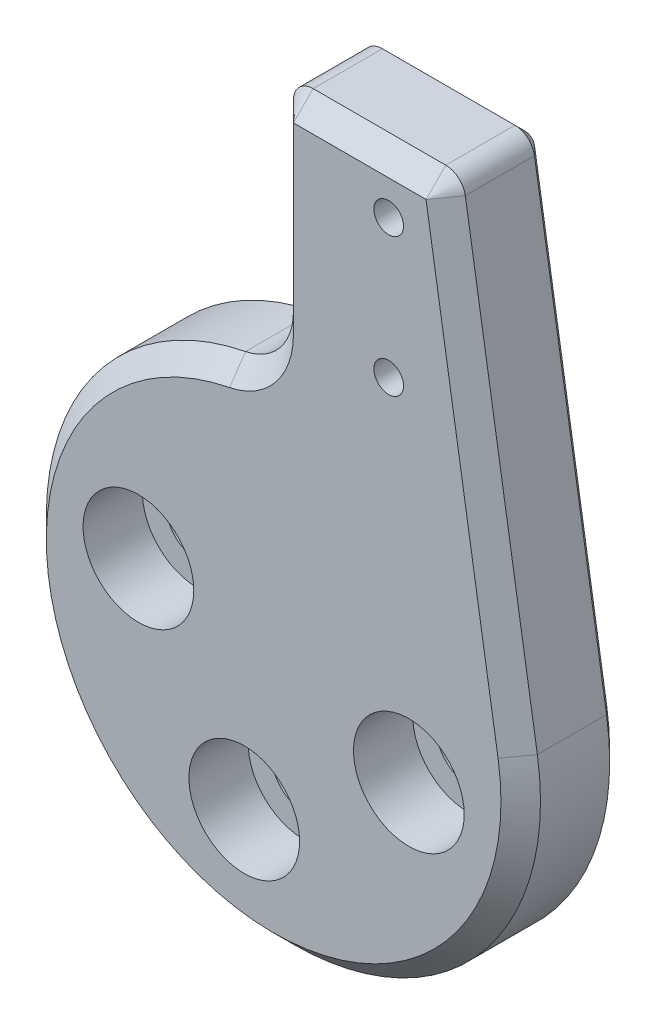
from build123d import *

# Parameters (mm, degrees)
SKETCH1_R           = 1.6
SKETCH1_R_2         = 1.6000000000000016
SKETCH1_R_3         = 0.7500000000000004
BOSS_EXTRUDE1_DEPTH = 5
CHAMFER1_SIZE       = 1
SKETCH2_R           = 2.8000000000000003
SKETCH2_R_2         = 2.8
CUT_EXTRUDE1_DEPTH  = 3
CHAMFER3_SIZE       = 0.5


with BuildPart() as part:
    # Sketch1 → Boss-Extrude1 (new body)
    with BuildSketch(Plane.XY):
        with BuildLine():
            Line((1.000000000000007, 25.491602871293395), (7.708608571885691, 25.491602871293395))
            ThreePointArc((7.708608571885691, 25.491602871293395), (8.357146361630761, 25.2527853298883), (8.695919750465407, 24.650400341838562))
            Line((8.695919750465407, 24.650400341838562), (12.341389732124407, 1.9849683817950852))
            ThreePointArc((12.341389732124407, 1.9849683817950852), (-7.1431391219536895, -10.257951232157744), (-2.41935483870505, 12.263634133540775))
            ThreePointArc((-2.41935483870505, 12.263634133540775), (-0.6824651584188808, 13.301904420618609), (-1e-17, 15.206906325619645))
            Line((-1e-17, 15.206906325619645), (-3e-17, 24.491602871293384))
            ThreePointArc((-3e-17, 24.491602871293384), (0.2928932188134522, 25.198709652479938), (1.000000000000007, 25.491602871293395))
        make_face()
        with Locations((-6.84012746585444, 1.4874999998823886)):
            Circle(SKETCH1_R, mode=Mode.SUBTRACT)
        with Locations((-1.487499999936831, -6.840127466035101)):
            Circle(SKETCH1_R, mode=Mode.SUBTRACT)
        with Locations((6.840127465980755, -1.4875000001175058)):
            Circle(SKETCH1_R_2, mode=Mode.SUBTRACT)
        with Locations((5.820860522174176, 15.749999999999972)):
            Circle(SKETCH1_R_3, mode=Mode.SUBTRACT)
        with Locations((5.820860522174148, 22.74999999999998)):
            Circle(SKETCH1_R_3, mode=Mode.SUBTRACT)
    extrude(amount=BOSS_EXTRUDE1_DEPTH)

    # Chamfer1
    chamfer1_edges = [part.edges().sort_by_distance(p)[0] for p in [
        (-0.6824651584188803, 13.301904420618609, 5),
        (-7.143139121953682, -10.25795123215775, 5),
        (10.518654741294906, 13.317684361816823, 5),
        (8.357146361630761, 25.2527853298883, 5),
        (4.354304285942849, 25.491602871293395, 5),
        (0.2928932188134533, 25.198709652479938, 5),
        (-2e-17, 19.849254598456515, 5),
    ]]
    chamfer(chamfer1_edges, length=CHAMFER1_SIZE)

    # Sketch2 → Cut-Extrude1 (cut)
    with BuildSketch(Plane.XY.offset(5)):
        with Locations((-6.84012746585444, 1.4874999998823886)):
            Circle(SKETCH2_R)
        with Locations((-1.487499999936831, -6.840127466035101)):
            Circle(SKETCH2_R_2)
        with Locations((6.840127465980755, -1.4875000001175058)):
            Circle(SKETCH2_R)
    extrude(amount=-CUT_EXTRUDE1_DEPTH, mode=Mode.SUBTRACT)

    # Chamfer3
    chamfer3_edges = [part.edges().sort_by_distance(p)[0] for p in [
        (-2e-17, 19.849254598456515, 0),
        (0.2928932188134533, 25.198709652479938, 0),
        (4.354304285942849, 25.491602871293395, 0),
        (8.357146361630761, 25.2527853298883, 0),
        (10.518654741294906, 13.317684361816823, 0),
        (-7.143139121953682, -10.25795123215775, 0),
        (-0.6824651584188803, 13.301904420618609, 0),
    ]]
    chamfer(chamfer3_edges, length=CHAMFER3_SIZE)


solid = part.part
